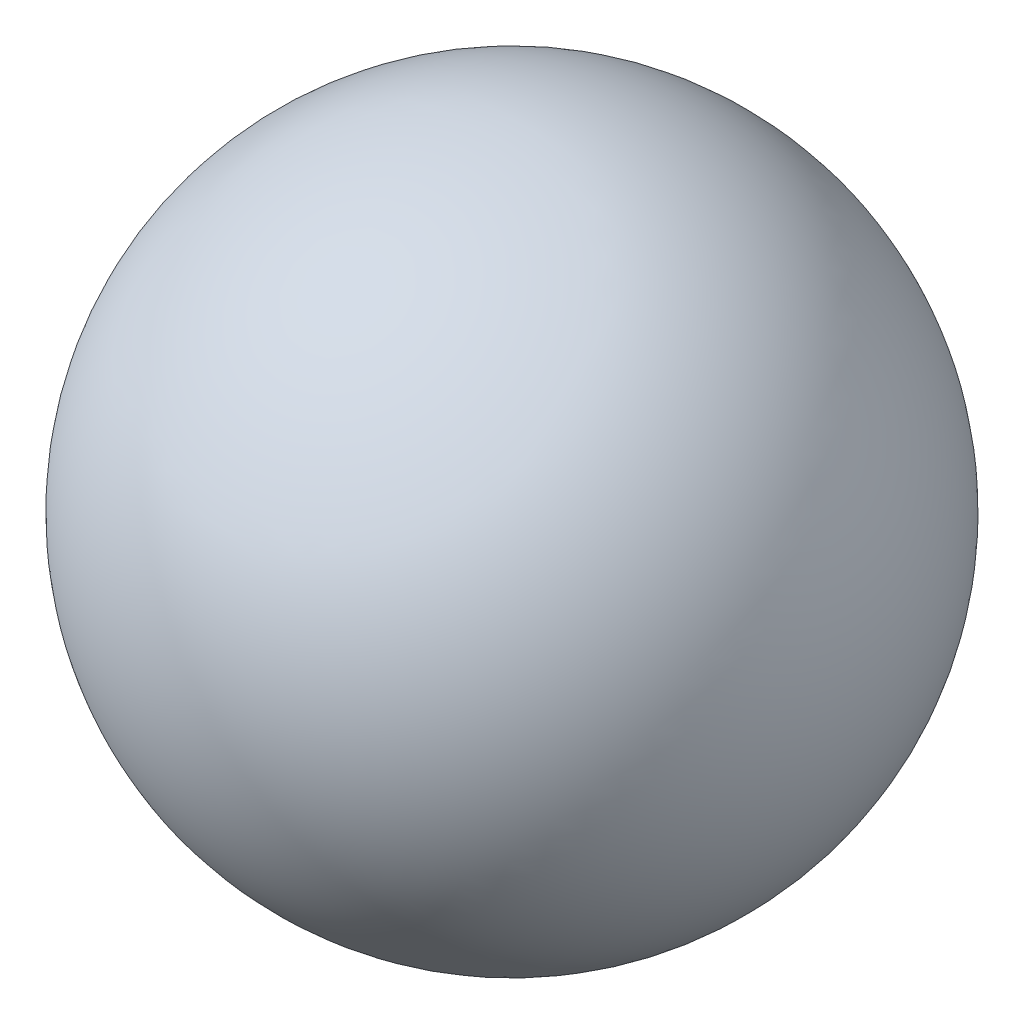
from build123d import *


with BuildPart() as part:
    # Sketch1 → Revolve1 (revolve)
    with BuildSketch(Plane(origin=(0, 0, 0), x_dir=(1, 0, 0), z_dir=(0, 1, 0))):
        with BuildLine():
            Line((0, 1.8), (0, -1.8))
            ThreePointArc((0, -1.8), (-1.8, 0), (0, 1.8))
        make_face()
    revolve(axis=Axis((0, 0, -1.8), (0, 0, 1)))


solid = part.part
